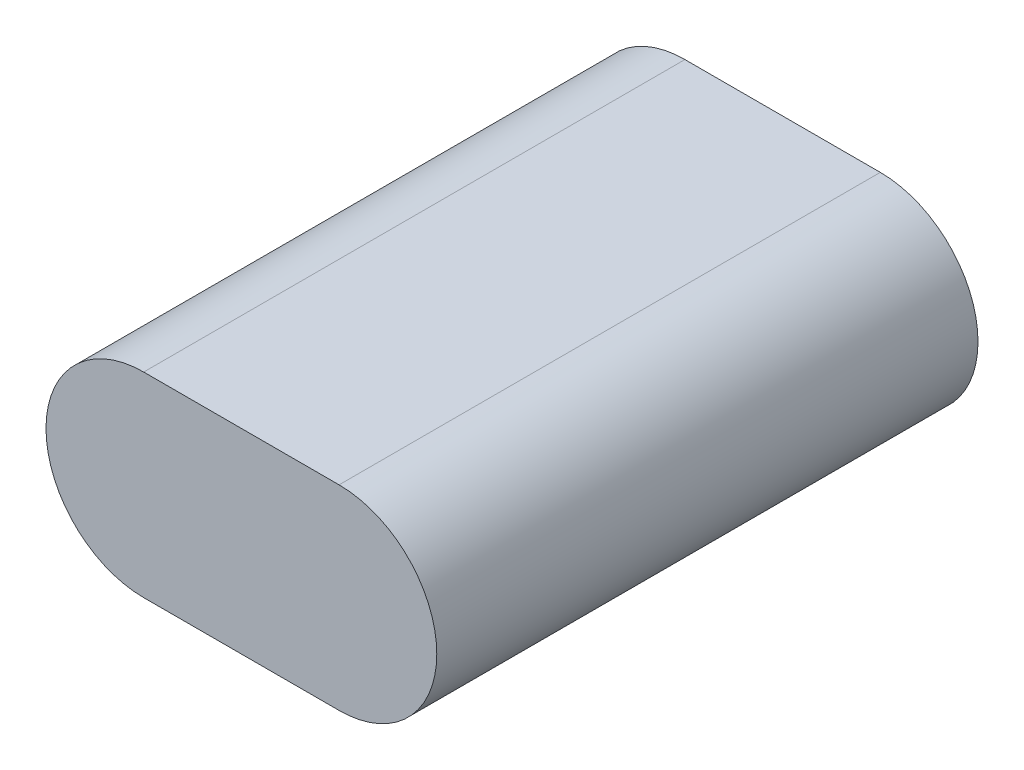
from build123d import *

# Parameters (mm, degrees)
EXTRUDE_1_DEPTH = 138.5


with BuildPart() as part:
    # 草图1 → 凸台-拉伸1 (new body, symmetric)
    with BuildSketch(Plane.XY):
        with BuildLine():
            Line((-50, 50), (50, 50))
            ThreePointArc((50, 50), (100, 0), (50, -50))
            Line((50, -50), (-50, -50))
            ThreePointArc((-50, -50), (-100, 0), (-50, 50))
        make_face()
    extrude(amount=EXTRUDE_1_DEPTH, both=True)


solid = part.part
